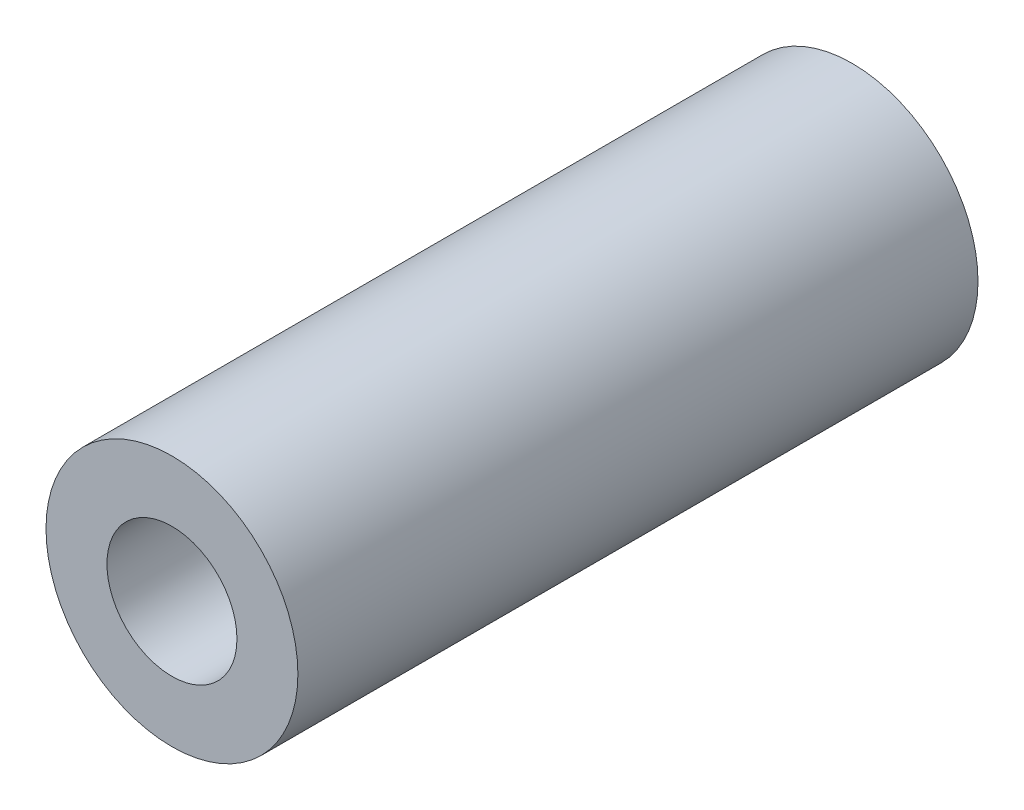
from build123d import *

# Parameters (mm, degrees)
ESBO_O1_R                = 3.1
ESBO_O1_R_2              = 1.55
RESSALTO_EXTRUS_O1_DEPTH = 16.74
M3_CLEARANCE_HOLE1_D     = 3.2


with BuildPart() as part:
    # Esboço1 → Ressalto-extrusão1 (new body)
    with BuildSketch(Plane.XY):
        with Locations((16.016666667, 16.016666667)):
            Circle(ESBO_O1_R)
        with Locations((16.016666667, 16.016666667)):
            Circle(ESBO_O1_R_2, mode=Mode.SUBTRACT)
    extrude(amount=RESSALTO_EXTRUS_O1_DEPTH)

    # M3 Clearance Hole1 (through all)
    with Locations(Plane(origin=(16.016666667, 16.016666667, 16.74), x_dir=(1, 0, 0), z_dir=(0, 0, 1))):
        with Locations((0, 0)):
            Hole(M3_CLEARANCE_HOLE1_D / 2)


solid = part.part
